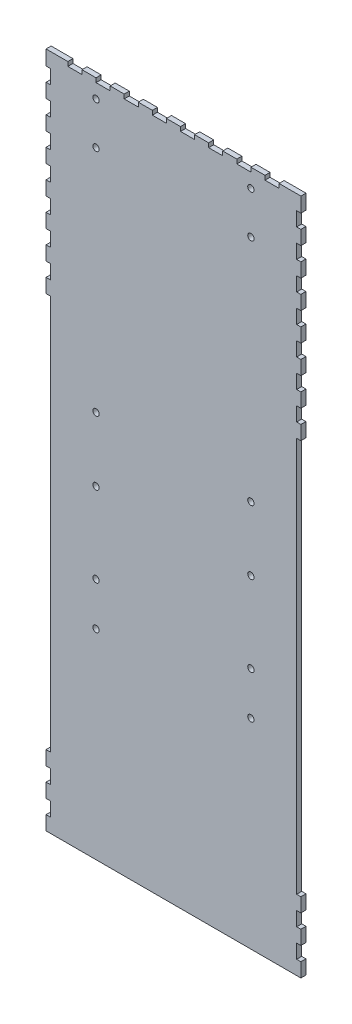
from build123d import *

# Parameters (mm, degrees)
BOSS_EXTRUDE1_DEPTH = 3.6
SKETCH3_R           = 2.25
CUT_EXTRUDE1_DEPTH  = 10


with BuildPart() as part:
    # Sketch1 → Boss-Extrude1 (new body)
    with BuildSketch(Plane.XY):
        Polygon((3, 408), (-12.5, 408), (-12.5, 405), (-22.5, 405), (-22.5, 408), (-32.5, 408), (-32.5, 405), (-42.5, 405), (-42.5, 408), (-52.5, 408), (-52.5, 405), (-62.5, 405), (-62.5, 408), (-72.5, 408), (-72.5, 405), (-82.5, 405), (-82.5, 408), (-92.5, 408), (-92.5, 405), (-102.5, 405), (-102.5, 408), (-112.5, 408), (-112.5, 405), (-122.5, 405), (-122.5, 408), (-132.5, 408), (-132.5, 405), (-142.5, 405), (-142.5, 408), (-152.5, 408), (-152.5, 405), (-162.5, 405), (-162.5, 408), (-178, 408), (-178, 397.5), (-175, 397.5), (-175, 387.5), (-178, 387.5), (-178, 377.5), (-175, 377.5), (-175, 367.5), (-178, 367.5), (-178, 357.5), (-175, 357.5), (-175, 347.5), (-178, 347.5), (-178, 337.5), (-175, 337.5), (-175, 327.5), (-178, 327.5), (-178, 317.5), (-175, 317.5), (-175, 307.5), (-178, 307.5), (-178, 297.5), (-175, 297.5), (-175, 287.5), (-178, 287.5), (-178, 277.5), (-175, 277.5), (-175, 267.5), (-178, 267.5), (-178, 257.5), (-175, 257.5), (-175, 0), (-175, -23), (-178, -23), (-178, -33), (-175, -33), (-175, -43), (-178, -43), (-178, -53), (-175, -53), (-175, -63), (-178, -63), (-178, -73), (3, -73), (3, -63), (0, -63), (0, -53), (3, -53), (3, -43), (0, -43), (0, -33), (3, -33), (3, -23), (0, -23), (0, 0), (0, 257.5), (3, 257.5), (3, 267.5), (0, 267.5), (0, 277.5), (3, 277.5), (3, 287.5), (0, 287.5), (0, 297.5), (3, 297.5), (3, 307.5), (0, 307.5), (0, 317.5), (3, 317.5), (3, 327.5), (0, 327.5), (0, 337.5), (3, 337.5), (3, 347.5), (0, 347.5), (0, 357.5), (3, 357.5), (3, 367.5), (0, 367.5), (0, 377.5), (3, 377.5), (3, 387.5), (0, 387.5), (0, 397.5), (3, 397.5), align=None)
    extrude(amount=BOSS_EXTRUDE1_DEPTH)

    # Sketch3 → Cut-Extrude1 (cut)
    with BuildSketch(Plane.XY.offset(3.6)):
        with Locations((-142.5, 365)):
            Circle(SKETCH3_R)
        with Locations((-32.5, 69.049357195)):
            Circle(SKETCH3_R)
        with Locations((-32.5, 99.549357195)):
            Circle(SKETCH3_R)
        with Locations((-142.5, 69.049357195)):
            Circle(SKETCH3_R)
        with Locations((-142.5, 99.549357195)):
            Circle(SKETCH3_R)
        with Locations((-142.5, 156.719761425)):
            Circle(SKETCH3_R)
        with Locations((-32.5, 156.719761425)):
            Circle(SKETCH3_R)
        with Locations((-32.5, 202.219761425)):
            Circle(SKETCH3_R)
        with Locations((-142.5, 202.219761425)):
            Circle(SKETCH3_R)
        with Locations((-32.5, 365)):
            Circle(SKETCH3_R)
        with Locations((-32.5, 395)):
            Circle(SKETCH3_R)
        with Locations((-142.5, 395)):
            Circle(SKETCH3_R)
    extrude(amount=-CUT_EXTRUDE1_DEPTH, mode=Mode.SUBTRACT)


solid = part.part
